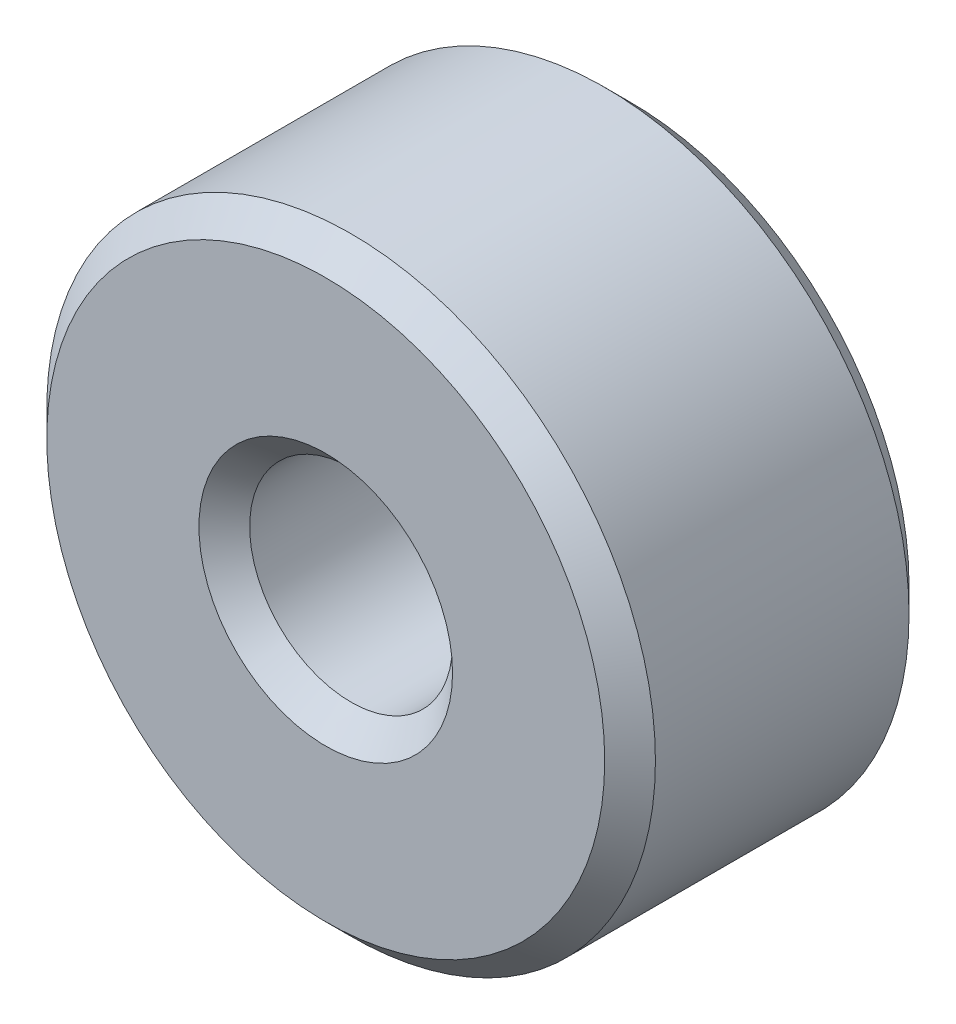
from build123d import *

# Parameters (mm, degrees)
SKETCH1_R           = 3
SKETCH1_R_2         = 1
EXTRUDE_THIN1_DEPTH = 3
CHAMFER1_SIZE       = 0.25
SCALE1_SCALE        = 10


with BuildPart() as part:
    # Sketch1 → Extrude-Thin1 (new body)
    with BuildSketch(Plane.XY):
        Circle(SKETCH1_R)
        Circle(SKETCH1_R_2, mode=Mode.SUBTRACT)
    extrude(amount=EXTRUDE_THIN1_DEPTH)

    # Chamfer1
    chamfer1_edges = [part.edges().sort_by_distance(p)[0] for p in [
        (-3, 0, 0),
        (-1, 0, 0),
        (-3, 0, 3),
        (-1, 0, 3),
    ]]
    chamfer(chamfer1_edges, length=CHAMFER1_SIZE)


with BuildPart() as part_1:
    # Scale1: scaled about (0, 0, 1.5)
    add(part.part.scale(SCALE1_SCALE).moved(Location((0, 0, -13.5))))


solid = part_1.part
